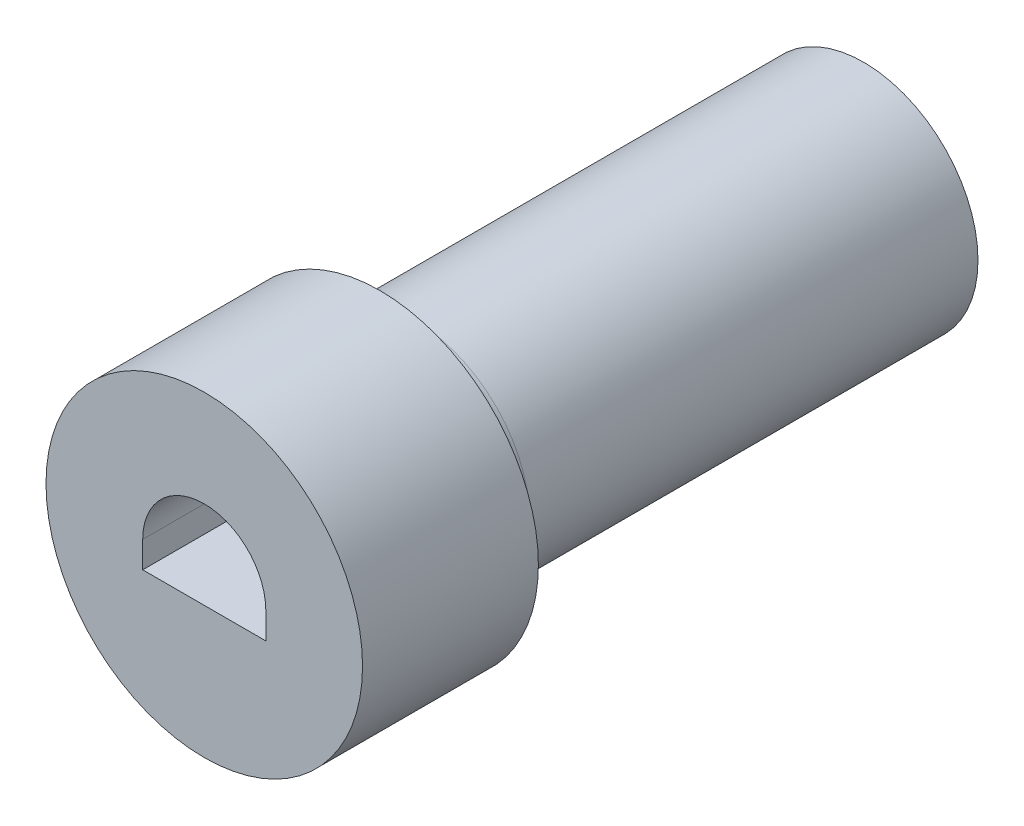
from build123d import *

# Parameters (mm, degrees)
SKETCH1_R               = 1.651
BOSS_EXTRUDE1_DEPTH     = 6.985
SKETCH3_R               = 2.286
BOSS_EXTRUDE2_DEPTH     = 2.54
CUT_EXTRUDE3_DEPTH      = 2.54
CUT_EXTRUDE3_DEPTH_BACK = 2.54
FILLET1_R               = 0.508


with BuildPart() as part:
    # Sketch1 → Boss-Extrude1 (new body)
    with BuildSketch(Plane.XY):
        Circle(SKETCH1_R)
    extrude(amount=BOSS_EXTRUDE1_DEPTH)

    # Sketch3 → Boss-Extrude2 (add)
    with BuildSketch(Plane.XY.offset(6.985)):
        Circle(SKETCH3_R)
    extrude(amount=BOSS_EXTRUDE2_DEPTH)

    # Sketch2 → Cut-Extrude3 (cut, two sides)
    with BuildSketch(Plane.XY.offset(6.985)) as cut_extrude3_sk:
        with BuildLine():
            Line((-0.889, 0), (-0.889, -0.381))
            Line((-0.889, -0.381), (0.7112, -0.381))
            Line((0.7112, -0.381), (0.889, -0.381))
            Line((0.889, -0.381), (0.889, 0))
            ThreePointArc((0.889, 0), (0, 0.889), (-0.889, 0))
        make_face()
    extrude(amount=CUT_EXTRUDE3_DEPTH, mode=Mode.SUBTRACT)
    extrude(cut_extrude3_sk.sketch, amount=-CUT_EXTRUDE3_DEPTH_BACK, mode=Mode.SUBTRACT)

    # Fillet1
    fillet1_edges = [part.edges().sort_by_distance(p)[0] for p in [
        (-1.651, 0, 6.985),
    ]]
    fillet(fillet1_edges, radius=FILLET1_R)


solid = part.part
